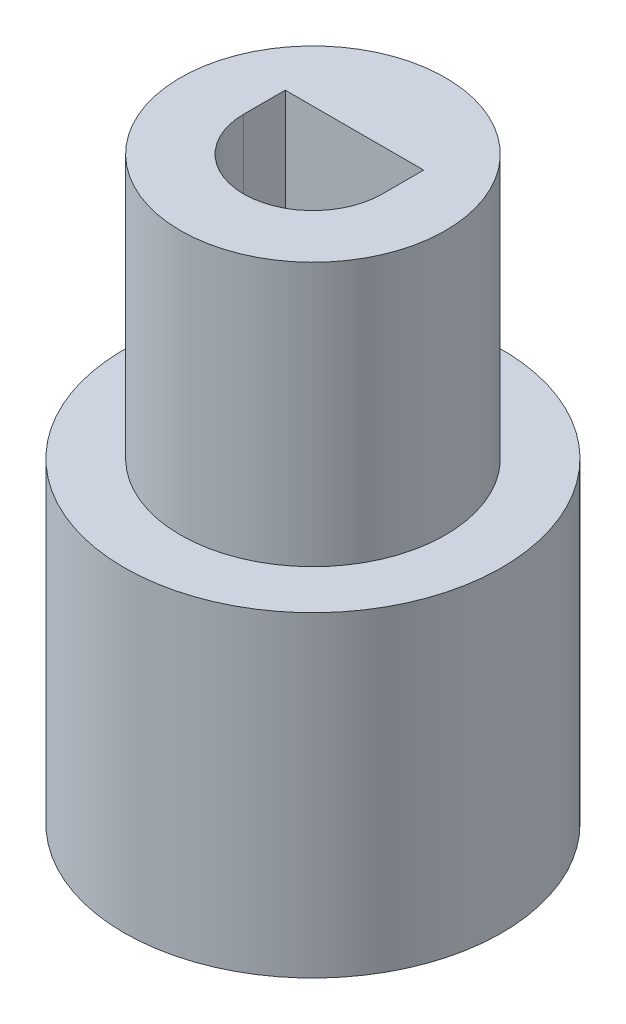
from build123d import *

# Parameters (mm, degrees)
SKETCH1_R           = 7.1625
SKETCH1_R_2         = 4.7625
BOSS_EXTRUDE1_DEPTH = 10
SKETCH2_R           = 7.1625
SKETCH2_R_2         = 4.7625
BOSS_EXTRUDE2_DEPTH = 2
SKETCH3_R           = 5.025
BOSS_EXTRUDE3_DEPTH = 10


with BuildPart() as part:
    # Sketch1 → Boss-Extrude1 (new body)
    with BuildSketch(Plane(origin=(0, 0, 0), x_dir=(1, 0, 0), z_dir=(0, 1, 0))):
        Circle(SKETCH1_R)
        Circle(SKETCH1_R_2, mode=Mode.SUBTRACT)
    extrude(amount=BOSS_EXTRUDE1_DEPTH)

    # Sketch2 → Boss-Extrude2 (add)
    with BuildSketch(Plane(origin=(0, 10, 0), x_dir=(1, 0, 0), z_dir=(0, 1, 0))):
        Circle(SKETCH2_R)
        Circle(SKETCH2_R_2, mode=Mode.SUBTRACT)
        Circle(SKETCH2_R_2)
    extrude(amount=BOSS_EXTRUDE2_DEPTH)

    # Sketch3 → Boss-Extrude3 (add)
    with BuildSketch(Plane(origin=(0, 12, 0), x_dir=(1, 0, 0), z_dir=(0, 1, 0))):
        Circle(SKETCH3_R)
        with BuildLine():
            Line((-2.625, 0), (-2.625, 1.575))
            Line((-2.625, 1.575), (2.625, 1.575))
            Line((2.625, 1.575), (2.625, 0))
            ThreePointArc((2.625, 0), (0, -2.625), (-2.625, 0))
        make_face(mode=Mode.SUBTRACT)
    extrude(amount=BOSS_EXTRUDE3_DEPTH)


solid = part.part
